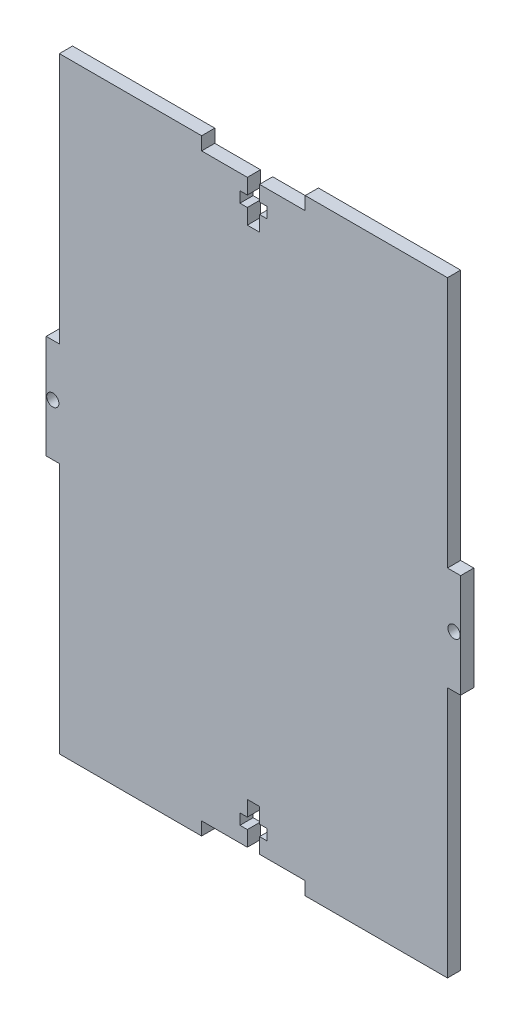
from build123d import *

# Parameters (mm, degrees)
SKETCH1_R           = 1.47
BOSS_EXTRUDE1_DEPTH = 1.5875


with BuildPart() as part:
    # Sketch1 → Boss-Extrude1 (new body, symmetric)
    with BuildSketch(Plane.XY):
        Polygon((-12.5, 73.175), (-46.825, 73.175), (-46.825, 12.5), (-50, 12.5), (-50, -12.5), (-46.825, -12.5), (-46.825, -73.175), (-12.5, -73.175), (-12.5, -70), (-1.47, -70), (-1.47, -66.3), (-3.25, -66.3), (-3.25, -63.7), (-1.47, -63.7), (-1.47, -60), (1.47, -60), (1.47, -63.7), (3.25, -63.7), (3.25, -66.3), (1.47, -66.3), (1.47, -70), (12.5, -70), (12.5, -73.175), (46.825, -73.175), (46.825, -12.5), (50, -12.5), (50, 12.5), (46.825, 12.5), (46.825, 73.175), (12.5, 73.175), (12.5, 70), (1.47, 70), (1.47, 66.3), (3.25, 66.3), (3.25, 63.7), (1.47, 63.7), (1.47, 60), (-1.47, 60), (-1.47, 63.7), (-3.25, 63.7), (-3.25, 66.3), (-1.47, 66.3), (-1.47, 70), (-12.5, 70), align=None)
        with Locations((-48.4125, 0)):
            Circle(SKETCH1_R, mode=Mode.SUBTRACT)
        with Locations((48.4125, 0)):
            Circle(SKETCH1_R, mode=Mode.SUBTRACT)
    extrude(amount=BOSS_EXTRUDE1_DEPTH, both=True)


solid = part.part
